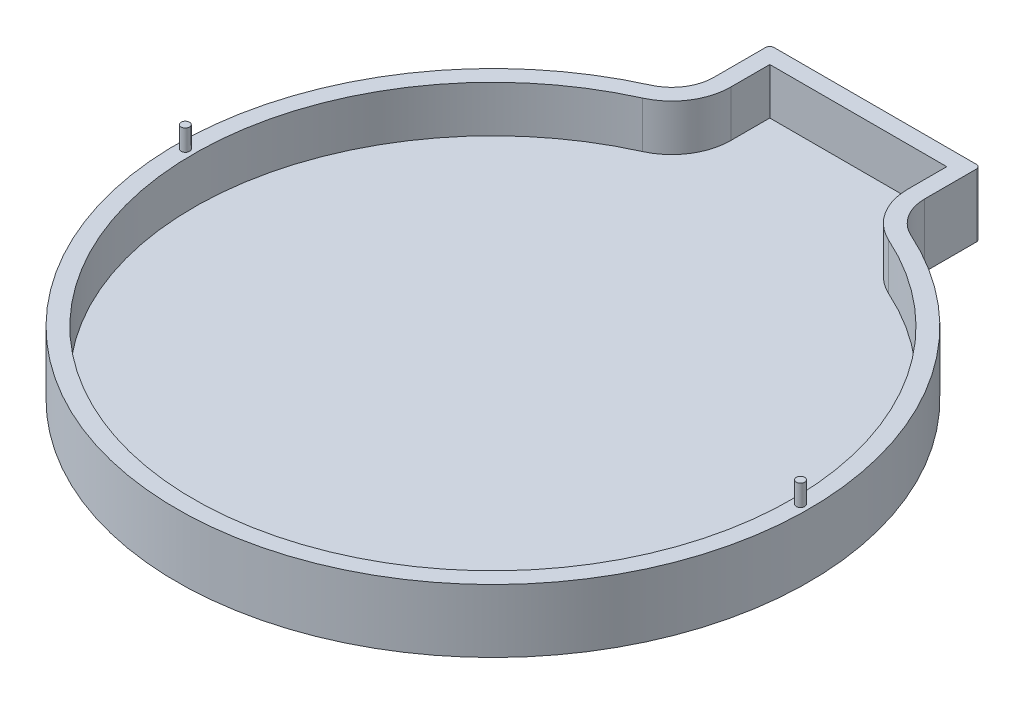
from build123d import *

# Parameters (mm, degrees)
BOSS_EXTRUDE1_DEPTH = 15
FILLET2_R           = 10
SHELL1_T            = -4
SKETCH7_R           = 1
BOSS_EXTRUDE4_DEPTH = 5


with BuildPart() as part:
    # Sketch1 → Boss-Extrude1 (new body)
    with BuildSketch(Plane(origin=(0, 0, 0), x_dir=(1, 0, 0), z_dir=(0, 1, 0))):
        with BuildLine():
            Line((-24, 90.710678119), (24, 90.710678119))
            ThreePointArc((24, 90.710678119), (24.707106781, 90.4177849), (25, 89.710678119))
            Line((25, 89.710678119), (25, 70.710678119))
            ThreePointArc((25, 70.710678119), (0, -75), (-25, 70.710678119))
            Line((-25, 70.710678119), (-25, 89.710678119))
            ThreePointArc((-25, 89.710678119), (-24.707106781, 90.4177849), (-24, 90.710678119))
        make_face()
    extrude(amount=BOSS_EXTRUDE1_DEPTH)

    # Fillet2
    fillet2_edges = [part.edges().sort_by_distance(p)[0] for p in [
        (25, 7.5, -70.710678119),
        (-25, 7.5, -70.710678119),
    ]]
    fillet(fillet2_edges, radius=FILLET2_R)

    # Shell1
    shell1_openings = [part.faces().sort_by_distance(p)[0] for p in [
        (0, 15, -3.849203435),
    ]]
    offset(amount=SHELL1_T, openings=shell1_openings)

    # Sketch7 → Boss-Extrude4 (add)
    with BuildSketch(Plane(origin=(0, 15, 0), x_dir=(1, 0, 0), z_dir=(0, 1, 0))):
        with Locations(Location((-73, 0, 0), (0, 0, 90))):  # turned: the seam where the file's is
            Circle(SKETCH7_R)
        with Locations(Location((73, 0, 0), (0, 0, 90))):  # turned: the seam where the file's is
            Circle(SKETCH7_R)
    extrude(amount=BOSS_EXTRUDE4_DEPTH)


solid = part.part
